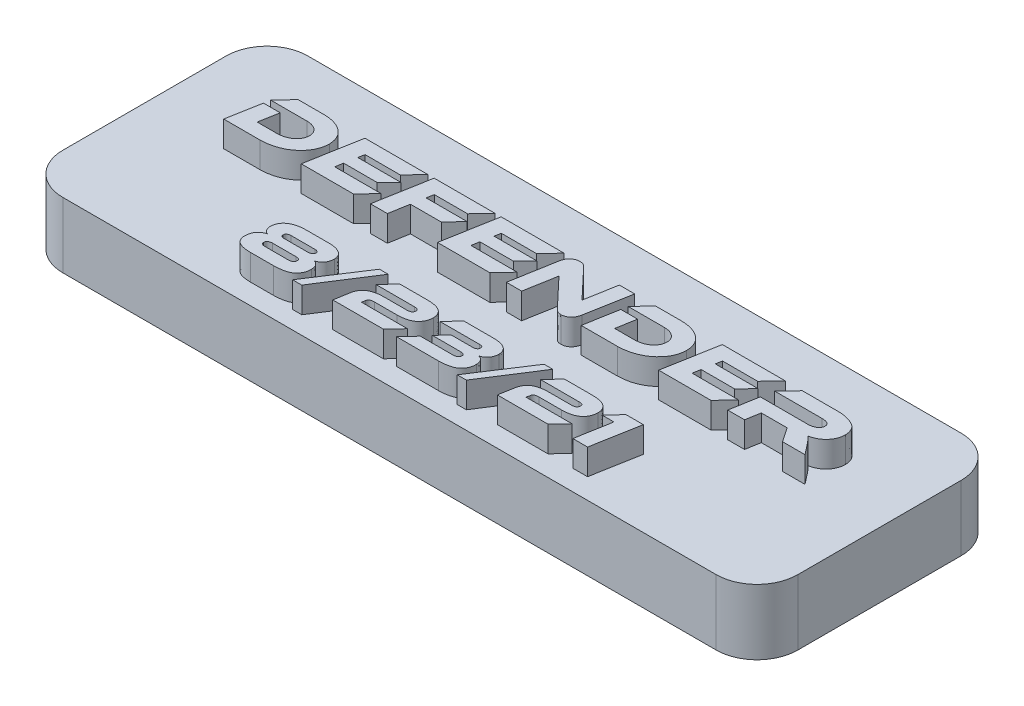
from build123d import *

# Parameters (mm, degrees)
SKETCH1_W           = 57.15
SKETCH1_H           = 19.05
BOSS_EXTRUDE1_DEPTH = 5.08
FILLET1_R           = 3.175
BOSS_EXTRUDE2_DEPTH = 2
SKETCH4_R           = 0.9
CUT_EXTRUDE1_DEPTH  = 4


with BuildPart() as part:
    # Sketch1 → Boss-Extrude1 (new body)
    with BuildSketch(Plane(origin=(0, 0, 0), x_dir=(1, 0, 0), z_dir=(0, 1, 0))):
        Rectangle(SKETCH1_W, SKETCH1_H)
    extrude(amount=BOSS_EXTRUDE1_DEPTH)

    # Fillet1
    fillet1_edges = [part.edges().sort_by_distance(p)[0] for p in [
        (-28.575, 2.54, -9.525),
        (-28.575, 2.54, 9.525),
        (28.575, 2.54, 9.525),
        (28.575, 2.54, -9.525),
    ]]
    fillet(fillet1_edges, radius=FILLET1_R)

    # Sketch3 → Boss-Extrude2 (add)
    with BuildSketch(Plane(origin=(0, 5.08, 0), x_dir=(1, 0, 0), z_dir=(0, 1, 0))):
        with BuildLine():
            add(Edge.make_bspline(
                [(22.1380192, 0.821261664), (22.110233075, 0.855514425), (22.057323504, 0.920737585), (21.983538164, 1.014147602), (21.914934978, 1.094728322), (21.854568887, 1.165931133), (21.798587752, 1.228233858), (21.747083376, 1.283693514), (21.698500493, 1.332710365), (21.666196618, 1.361916294), (21.650837295, 1.375802657)],
                knots=[0, 0, 0, 0, 0.000132319, 0.000251958, 0.000357066, 0.000449775, 0.000531993, 0.000608312, 0.000676831, 0.00073894, 0.00073894, 0.00073894, 0.00073894], degree=3))
            add(Edge.make_bspline(
                [(21.650837295, 1.375802657), (21.701282217, 1.387655917), (21.800614927, 1.41099655), (21.944581947, 1.456505146), (22.080420679, 1.512656797), (22.208390222, 1.577599655), (22.329176828, 1.650662326), (22.440901248, 1.734287933), (22.544639127, 1.827209607), (22.640194594, 1.928008098), (22.726061409, 2.036209783), (22.802275017, 2.148795776), (22.865521287, 2.26744033), (22.919187232, 2.389702633), (22.959689614, 2.517720245), (22.991843394, 2.649747841), (23.009453089, 2.787111939), (23.013584533, 2.88015474), (23.015670097, 2.927122995)],
                knots=[0, 0, 0, 0, 0.000155422, 0.000306047, 0.000452383, 0.000595882, 0.000736201, 0.000875336, 0.001013884, 0.001153561, 0.001291475, 0.00142788, 0.00156081, 0.001694289, 0.00182785, 0.001963107, 0.002101444, 0.002242464, 0.002242464, 0.002242464, 0.002242464], degree=3))
            add(Edge.make_bspline(
                [(23.015670097, 2.927122995), (23.01100645, 2.986733362), (23.002007489, 3.101757358), (22.965601322, 3.266295736), (22.913015681, 3.416602664), (22.842054216, 3.55250609), (22.753525997, 3.674215745), (22.645724254, 3.779555576), (22.522378714, 3.872802597), (22.380746955, 3.946152329), (22.230953308, 4.009923214), (22.076663938, 4.066098529), (21.918546122, 4.111445148), (21.757558489, 4.149301444), (21.592991154, 4.17747869), (21.425448915, 4.196572697), (21.254841422, 4.207081738), (21.140142863, 4.20637971), (21.08223314, 4.206025266)],
                knots=[0, 0, 0, 0, 0.000179195, 0.000345775, 0.000503934, 0.000655634, 0.000804102, 0.000953423, 0.00110627, 0.001266195, 0.001430402, 0.00159465, 0.001758393, 0.001923592, 0.002090563, 0.002258951, 0.002429281, 0.002602973, 0.002602973, 0.002602973, 0.002602973], degree=3))
            Line((21.08223314, 4.206025266), (18.365733505, 4.206347541))
            Line((18.365733505, 4.206347541), (17.316823245, 3.106887389))
            Line((17.316823245, 3.106887389), (20.994327892, 3.106887389))
            add(Edge.make_bspline(
                [(20.994327892, 3.106887389), (21.042289442, 3.105563142), (21.133101198, 3.103055777), (21.261206009, 3.084102014), (21.372826302, 3.053127658), (21.467185876, 3.008361144), (21.543352194, 2.950733271), (21.599088606, 2.878524615), (21.63231527, 2.792039639), (21.636080617, 2.729960255), (21.63803913, 2.697670193)],
                knots=[0, 0, 0, 0, 0.000143839, 0.000272348, 0.000387495, 0.000490117, 0.000583924, 0.00067132, 0.000760449, 0.00085706, 0.00085706, 0.00085706, 0.00085706], degree=3))
            add(Edge.make_bspline(
                [(21.63803913, 2.697670193), (21.636362091, 2.677195647), (21.6330541, 2.636809238), (21.620272862, 2.578009425), (21.600164385, 2.522994029), (21.572773444, 2.47158108), (21.539382067, 2.423095084), (21.497445133, 2.378841184), (21.448426997, 2.338813063), (21.374748783, 2.288346001), (21.270134405, 2.236864834), (21.132655227, 2.191707585), (20.98204979, 2.165412454), (20.877564865, 2.161339559), (20.823527391, 2.15923314)],
                knots=[0, 0, 0, 0, 6.1582e-05, 0.000121471, 0.000179891, 0.000236731, 0.000295819, 0.000355966, 0.000418937, 0.000485369, 0.000623551, 0.000766937, 0.000918284, 0.001080402, 0.001080402, 0.001080402, 0.001080402], degree=3))
            Line((20.823527391, 2.15923314), (17.146217359, 2.159459893))
            Line((17.146217359, 2.159459893), (16.767093168, 0.003655726))
            Line((16.767093168, 0.003655726), (18.075071626, 0.003655726))
            Line((18.075071626, 0.003655726), (18.270952457, 1.11686837))
            Line((18.270952457, 1.11686837), (20.280310667, 1.11686837))
            Line((20.280310667, 1.11686837), (21.025921574, 0.003655726))
            Line((21.025921574, 0.003655726), (22.776211587, 0.003655726))
            Line((22.776211587, 0.003655726), (22.1380192, 0.821261664))
        make_face()
        Polygon((12.901047708, 1.105536066), (13.002147492, 1.700326644), (15.605466933, 1.700326644), (16.51536499, 2.629107706), (13.172753378, 2.629107706), (13.261215689, 3.106887389), (15.997228597, 3.106887389), (17.03982012, 4.206347541), (12.149118064, 4.206347541), (11.397188419, 0.006075914), (15.46645473, 0.006075914), (16.502727517, 1.105536066), align=None)
        with BuildLine():
            add(Edge.make_bspline(
                [(11.159044007, 2.425376215), (11.156168293, 2.490366785), (11.150517883, 2.618064917), (11.118710503, 2.803986167), (11.070079895, 2.980115123), (11.004546328, 3.146960648), (10.918349172, 3.303299496), (10.81491754, 3.450058323), (10.692675159, 3.586303096), (10.554116067, 3.712179584), (10.399108664, 3.825344313), (10.230694299, 3.925395962), (10.048478763, 4.009390478), (9.853615227, 4.079106767), (9.645545385, 4.133528035), (9.424346333, 4.173811565), (9.189906687, 4.198189582), (9.029160673, 4.203371321), (8.946830966, 4.206025266)],
                knots=[0, 0, 0, 0, 0.000195009, 0.000383167, 0.000564368, 0.00074244, 0.000919581, 0.001098646, 0.001279935, 0.00146761, 0.001659228, 0.001854731, 0.002054318, 0.002260196, 0.002474835, 0.002698788, 0.00293411, 0.003181175, 0.003181175, 0.003181175, 0.003181175], degree=3))
            Line((8.946830966, 4.206025266), (6.950765493, 4.206347541))
            Line((6.950765493, 4.206347541), (5.920811442, 3.106887389))
            Line((5.920811442, 3.106887389), (8.751605398, 3.106887389))
            add(Edge.make_bspline(
                [(8.751605398, 3.106887389), (8.791117298, 3.105364711), (8.86833354, 3.102389015), (8.980955186, 3.089591847), (9.087648202, 3.069582481), (9.188496559, 3.04202105), (9.283858645, 3.008030543), (9.371989044, 2.964107485), (9.454852322, 2.914773344), (9.531615657, 2.858665576), (9.599530338, 2.795181395), (9.661208866, 2.72884043), (9.711039094, 2.655711823), (9.753852928, 2.579167986), (9.78808364, 2.49778013), (9.81107938, 2.411231968), (9.827610594, 2.320728819), (9.830337312, 2.258648084), (9.831732609, 2.22688058)],
                knots=[0, 0, 0, 0, 0.000118592, 0.000231759, 0.000339692, 0.000443921, 0.000545141, 0.000642853, 0.0007388, 0.00083424, 0.000927403, 0.001017368, 0.001105364, 0.001192113, 0.001280223, 0.00136938, 0.001460305, 0.001555592, 0.001555592, 0.001555592, 0.001555592], degree=3))
            add(Edge.make_bspline(
                [(9.831732609, 2.22688058), (9.829288164, 2.185642711), (9.824493425, 2.104755276), (9.801952724, 1.98706422), (9.76844647, 1.87545354), (9.721319, 1.770616802), (9.662073371, 1.672112744), (9.591784979, 1.579018173), (9.50720579, 1.493971369), (9.412767703, 1.414841832), (9.308550422, 1.343689091), (9.196895574, 1.281927096), (9.079262119, 1.227960987), (8.953992364, 1.185692043), (8.822831026, 1.150471437), (8.684482932, 1.126576329), (8.540156125, 1.109169924), (8.441357747, 1.106548421), (8.391024976, 1.105212899)],
                knots=[0, 0, 0, 0, 0.00012382, 0.000242871, 0.000358539, 0.000472706, 0.000586683, 0.000702784, 0.000821729, 0.000945681, 0.001071953, 0.001199634, 0.001328098, 0.001459638, 0.001595783, 0.001735109, 0.00188048, 0.002031451, 0.002031451, 0.002031451, 0.002031451], degree=3))
            Line((8.391024976, 1.105212899), (6.874940655, 1.105536066))
            Line((6.874940655, 1.105536066), (7.146646325, 2.623662059))
            Line((7.146646325, 2.623662059), (5.838667868, 2.623662059))
            Line((5.838667868, 2.623662059), (5.371081366, 0.006075914))
            Line((5.371081366, 0.006075914), (8.201875321, 0.006075914))
            add(Edge.make_bspline(
                [(8.201875321, 0.006075914), (8.303742698, 0.00973645), (8.503898635, 0.016928919), (8.797276314, 0.055361686), (9.077869848, 0.113609118), (9.345746371, 0.192345638), (9.601188437, 0.290947451), (9.843364969, 0.411678855), (10.07381561, 0.551302588), (10.253190091, 0.685730436), (10.388476432, 0.801137626), (10.483667045, 0.891127884), (10.573157595, 0.98286194), (10.656050912, 1.077854124), (10.732812359, 1.175378809), (10.802988026, 1.275986307), (10.867715967, 1.378755373), (10.924846299, 1.484675691), (10.976421352, 1.592866707), (11.021309622, 1.703675086), (11.059516561, 1.817381495), (11.092613976, 1.933500983), (11.119470155, 2.052449268), (11.137947308, 2.174419147), (11.152379566, 2.298802205), (11.156229286, 2.38285802), (11.159044007, 2.425376215)],
                knots=[0, 0, 0, 0, 0.000305659, 0.00060058, 0.000886364, 0.001164634, 0.001437273, 0.001706688, 0.001975409, 0.002244537, 0.002378097, 0.002508729, 0.002637378, 0.002762417, 0.002886772, 0.003009517, 0.003130255, 0.003250927, 0.003370328, 0.003489667, 0.003609348, 0.003730019, 0.003851781, 0.003974869, 0.004099948, 0.004227226, 0.004227226, 0.004227226, 0.004227226], degree=3))
        make_face()
        with BuildLine():
            add(Edge.make_bspline(
                [(3.850463767, -0.054850168), (3.898207164, -0.053307756), (3.992909305, -0.05024828), (4.130965687, -0.013632566), (4.261880399, 0.045846546), (4.363145933, 0.114571327), (4.440010596, 0.180074196), (4.491662878, 0.239380304), (4.539338865, 0.304525883), (4.583017611, 0.37632488), (4.619747247, 0.456142621), (4.652863868, 0.542520209), (4.68129352, 0.636006561), (4.695839595, 0.701351948), (4.703325362, 0.73498029)],
                knots=[0, 0, 0, 0, 0.000142918, 0.000283487, 0.000425039, 0.000572601, 0.000649052, 0.000727397, 0.000807848, 0.000891096, 0.000979017, 0.001071034, 0.001168489, 0.001271817, 0.001271817, 0.001271817, 0.001271817], degree=3))
            Line((4.703325362, 0.73498029), (5.32904811, 4.208766837))
            Line((5.32904811, 4.208766837), (4.141125646, 4.208766837))
            Line((4.141125646, 4.208766837), (3.698814091, 1.744535481))
            Line((3.698814091, 1.744535481), (1.518849996, 4.051761679))
            add(Edge.make_bspline(
                [(1.518849996, 4.051761679), (1.498010869, 4.071861366), (1.457946596, 4.110504029), (1.395368732, 4.159915527), (1.333330986, 4.198286334), (1.253493604, 4.234148727), (1.153217036, 4.262967857), (1.071894605, 4.265244744), (1.032080531, 4.266359469)],
                knots=[0, 0, 0, 0, 8.6821e-05, 0.000166918, 0.000238724, 0.000304999, 0.000429193, 0.000548317, 0.000548317, 0.000548317, 0.000548317], degree=3))
            add(Edge.make_bspline(
                [(1.032080531, 4.266359469), (0.982803487, 4.264808905), (0.885756899, 4.261755212), (0.744614186, 4.225895662), (0.610878482, 4.169094021), (0.508319479, 4.10078741), (0.431804247, 4.035125752), (0.379928882, 3.976716804), (0.331780493, 3.912614286), (0.289717796, 3.840326612), (0.252402196, 3.76109782), (0.22083087, 3.674633708), (0.192616086, 3.581734028), (0.179533433, 3.516584051), (0.172775217, 3.482928986)],
                knots=[0, 0, 0, 0, 0.000147522, 0.000290531, 0.000433852, 0.000581668, 0.000658119, 0.000735785, 0.0008155, 0.00089828, 0.000986201, 0.001077895, 0.001174211, 0.001277134, 0.001277134, 0.001277134, 0.001277134], degree=3))
            Line((0.172775217, 3.482928986), (-0.439958322, 0.003655726))
            Line((-0.439958322, 0.003655726), (0.747964142, 0.003655726))
            Line((0.747964142, 0.003655726), (1.183956961, 2.467622834))
            Line((1.183956961, 2.467622834), (3.363921056, 0.160396636))
            add(Edge.make_bspline(
                [(3.363921056, 0.160396636), (3.384638161, 0.140042889), (3.42424306, 0.101132624), (3.486374612, 0.052046216), (3.545934438, 0.012533377), (3.62346331, -0.024191848), (3.72515749, -0.051598076), (3.808187255, -0.054359084), (3.850463767, -0.054850168)],
                knots=[0, 0, 0, 0, 8.7067e-05, 0.000166446, 0.000237191, 0.000300979, 0.000423168, 0.000549653, 0.000549653, 0.000549653, 0.000549653], degree=3))
        make_face()
        Polygon((-4.299685046, 1.105536066), (-4.198585261, 1.700326644), (-1.59526582, 1.700326644), (-0.685367763, 2.629107706), (-4.027979376, 2.629107706), (-3.939517065, 3.106887389), (-1.203504157, 3.106887389), (-0.160912633, 4.206347541), (-5.05161469, 4.206347541), (-5.803544334, 0.006075914), (-1.734278024, 0.006075914), (-0.698005236, 1.105536066), align=None)
        Polygon((-10.258639231, 4.206347541), (-11.010568875, 0.003655726), (-9.696271682, 0.003655726), (-9.424566012, 1.53029389), (-7.029764876, 1.53029389), (-6.056679454, 2.565116885), (-9.241322653, 2.565116885), (-9.146541606, 3.106887389), (-6.562178374, 3.106887389), (-5.525905587, 4.206347541), align=None)
        Polygon((-14.889251809, 1.105536066), (-14.788152025, 1.700326644), (-12.184832584, 1.700326644), (-11.274934527, 2.629107706), (-14.617546139, 2.629107706), (-14.529083828, 3.106887389), (-11.79307092, 3.106887389), (-10.750479397, 4.206347541), (-15.641181453, 4.206347541), (-16.393111098, 0.006075914), (-12.323844787, 0.006075914), (-11.287572, 1.105536066), align=None)
        with BuildLine():
            add(Edge.make_bspline(
                [(-16.63125551, 2.425376215), (-16.634131224, 2.490366785), (-16.639781634, 2.618064917), (-16.671589014, 2.803986167), (-16.720219622, 2.980115123), (-16.785753189, 3.146960648), (-16.871950345, 3.303299496), (-16.975381976, 3.450058323), (-17.097624357, 3.586303096), (-17.23618345, 3.712179584), (-17.391190853, 3.825344313), (-17.559605218, 3.925395962), (-17.741820753, 4.009390478), (-17.93668429, 4.079106767), (-18.144754132, 4.133528035), (-18.365953184, 4.173811565), (-18.600392829, 4.198189582), (-18.761138844, 4.203371321), (-18.843468551, 4.206025266)],
                knots=[0, 0, 0, 0, 0.000195009, 0.000383167, 0.000564368, 0.00074244, 0.000919581, 0.001098646, 0.001279935, 0.00146761, 0.001659228, 0.001854731, 0.002054318, 0.002260196, 0.002474835, 0.002698788, 0.00293411, 0.003181175, 0.003181175, 0.003181175, 0.003181175], degree=3))
            Line((-18.843468551, 4.206025266), (-20.839534024, 4.206347541))
            Line((-20.839534024, 4.206347541), (-21.869488075, 3.106887389))
            Line((-21.869488075, 3.106887389), (-19.038694119, 3.106887389))
            add(Edge.make_bspline(
                [(-19.038694119, 3.106887389), (-18.999182219, 3.105364711), (-18.921965977, 3.102389015), (-18.809344331, 3.089591847), (-18.702651315, 3.069582481), (-18.601802958, 3.04202105), (-18.506440872, 3.008030543), (-18.418310473, 2.964107485), (-18.335447195, 2.914773344), (-18.25868386, 2.858665576), (-18.190769179, 2.795181395), (-18.129090651, 2.72884043), (-18.079260423, 2.655711823), (-18.036446589, 2.579167986), (-18.002215877, 2.49778013), (-17.979220137, 2.411231968), (-17.962688923, 2.320728819), (-17.959962205, 2.258648084), (-17.958566908, 2.22688058)],
                knots=[0, 0, 0, 0, 0.000118592, 0.000231759, 0.000339692, 0.000443921, 0.000545141, 0.000642853, 0.0007388, 0.00083424, 0.000927403, 0.001017368, 0.001105364, 0.001192113, 0.001280223, 0.00136938, 0.001460305, 0.001555592, 0.001555592, 0.001555592, 0.001555592], degree=3))
            add(Edge.make_bspline(
                [(-17.958566908, 2.22688058), (-17.961011353, 2.185642711), (-17.965806092, 2.104755276), (-17.988346793, 1.98706422), (-18.021853047, 1.87545354), (-18.068980517, 1.770616802), (-18.128226146, 1.672112744), (-18.198514538, 1.579018173), (-18.283093727, 1.493971369), (-18.377531814, 1.414841832), (-18.481749094, 1.343689091), (-18.593403943, 1.281927096), (-18.711037398, 1.227960987), (-18.836307153, 1.185692043), (-18.967468491, 1.150471437), (-19.105816585, 1.126576329), (-19.250143392, 1.109169924), (-19.34894177, 1.106548421), (-19.399274541, 1.105212899)],
                knots=[0, 0, 0, 0, 0.00012382, 0.000242871, 0.000358539, 0.000472706, 0.000586683, 0.000702784, 0.000821729, 0.000945681, 0.001071953, 0.001199634, 0.001328098, 0.001459638, 0.001595783, 0.001735109, 0.00188048, 0.002031451, 0.002031451, 0.002031451, 0.002031451], degree=3))
            Line((-19.399274541, 1.105212899), (-20.915358862, 1.105536066))
            Line((-20.915358862, 1.105536066), (-20.643653192, 2.623662059))
            Line((-20.643653192, 2.623662059), (-21.951631649, 2.623662059))
            Line((-21.951631649, 2.623662059), (-22.419218151, 0.006075914))
            Line((-22.419218151, 0.006075914), (-19.588424195, 0.006075914))
            add(Edge.make_bspline(
                [(-19.588424195, 0.006075914), (-19.486556819, 0.00973645), (-19.286400882, 0.016928919), (-18.993023203, 0.055361686), (-18.712429669, 0.113609118), (-18.444553146, 0.192345638), (-18.18911108, 0.290947451), (-17.946934548, 0.411678855), (-17.716483907, 0.551302588), (-17.537109425, 0.685730436), (-17.401823085, 0.801137626), (-17.306632471, 0.891127884), (-17.217141922, 0.98286194), (-17.134248605, 1.077854124), (-17.057487158, 1.175378809), (-16.987311491, 1.275986307), (-16.92258355, 1.378755373), (-16.865453218, 1.484675691), (-16.813878165, 1.592866707), (-16.768989895, 1.703675086), (-16.730782956, 1.817381495), (-16.697685541, 1.933500983), (-16.670829362, 2.052449268), (-16.652352209, 2.174419147), (-16.637919951, 2.298802205), (-16.634070231, 2.38285802), (-16.63125551, 2.425376215)],
                knots=[0, 0, 0, 0, 0.000305659, 0.00060058, 0.000886364, 0.001164634, 0.001437273, 0.001706688, 0.001975409, 0.002244537, 0.002378097, 0.002508729, 0.002637378, 0.002762417, 0.002886772, 0.003009517, 0.003130255, 0.003250927, 0.003370328, 0.003489667, 0.003609348, 0.003730019, 0.003851781, 0.003974869, 0.004099948, 0.004227226, 0.004227226, 0.004227226, 0.004227226], degree=3))
        make_face()
        Polygon((12.244882676, -5.218973535), (13.14609247, -5.218973535), (12.665078653, -7.93430124), (13.809559803, -7.93430124), (14.467498242, -4.256945902), (13.112919103, -4.256945902), align=None)
        with BuildLine():
            Line((7.428273562, -5.218973535), (10.419405457, -5.218973535))
            add(Edge.make_bspline(
                [(10.419405457, -5.218973535), (10.447106371, -5.218922741), (10.498952745, -5.218827674), (10.571681748, -5.225918073), (10.63320579, -5.242216387), (10.685036327, -5.26353583), (10.725129716, -5.294908436), (10.753443715, -5.334273792), (10.770995693, -5.381008794), (10.772220392, -5.4147712), (10.772854758, -5.432259348)],
                knots=[0, 0, 0, 0, 8.3099e-05, 0.000155531, 0.000218392, 0.000273538, 0.000322508, 0.000368908, 0.000417497, 0.000469711, 0.000469711, 0.000469711, 0.000469711], degree=3))
            add(Edge.make_bspline(
                [(10.772854758, -5.432259348), (10.772214965, -5.458018948), (10.77100536, -5.506720508), (10.750442975, -5.573936821), (10.717156599, -5.630194031), (10.667942975, -5.673414306), (10.604411877, -5.704561408), (10.52667771, -5.726311626), (10.43355255, -5.738498194), (10.366550906, -5.73961472), (10.330518207, -5.740215175)],
                knots=[0, 0, 0, 0, 7.6993e-05, 0.000145564, 0.000208395, 0.000270703, 0.000339032, 0.00041902, 0.000511893, 0.000619952, 0.000619952, 0.000619952, 0.000619952], degree=3))
            Line((10.330518207, -5.740215175), (8.572754712, -5.739416071))
            add(Edge.make_bspline(
                [(8.572754712, -5.739416071), (8.517152556, -5.740560639), (8.408899394, -5.742789025), (8.250904068, -5.753609346), (8.102184708, -5.772857955), (7.96256184, -5.798779792), (7.832298642, -5.833149331), (7.71121979, -5.875619954), (7.59895241, -5.92500466), (7.495750542, -5.98174212), (7.402281346, -6.047028209), (7.317755853, -6.120143527), (7.242355244, -6.201107035), (7.176354221, -6.289606037), (7.119972648, -6.385733808), (7.072876893, -6.489539314), (7.03392953, -6.600822081), (7.016607854, -6.678800473), (7.007794813, -6.718474855)],
                knots=[0, 0, 0, 0, 0.000166829, 0.000324804, 0.000474816, 0.000616477, 0.000750546, 0.000878553, 0.001001026, 0.001118108, 0.001231277, 0.001342418, 0.001452782, 0.001562526, 0.00167296, 0.001786425, 0.001904052, 0.002025887, 0.002025887, 0.002025887, 0.002025887], degree=3))
            Line((7.007794813, -6.718474855), (6.792450701, -7.932183575))
            Line((6.792450701, -7.932183575), (10.729023546, -7.932183575))
            Line((10.729023546, -7.932183575), (11.635762234, -6.970155942))
            Line((11.635762234, -6.970155942), (8.064096424, -6.970155942))
            Line((8.064096424, -6.970155942), (8.113856474, -6.707239748))
            add(Edge.make_bspline(
                [(8.113856474, -6.707239748), (8.117633997, -6.686112106), (8.124956754, -6.645156023), (8.153668107, -6.590591717), (8.1920288, -6.543848716), (8.243368132, -6.508043577), (8.304443599, -6.47963759), (8.376761219, -6.461031101), (8.45982464, -6.450993538), (8.51874815, -6.450679637), (8.549973605, -6.450513291)],
                knots=[0, 0, 0, 0, 6.4036e-05, 0.000124134, 0.000182613, 0.000243892, 0.000310094, 0.000383827, 0.000466868, 0.000560486, 0.000560486, 0.000560486, 0.000560486], degree=3))
            Line((8.549973605, -6.450513291), (10.308827568, -6.449714187))
            add(Edge.make_bspline(
                [(10.308827568, -6.449714187), (10.374508593, -6.448593152), (10.501843033, -6.446419826), (10.685740882, -6.426694059), (10.857157493, -6.400940141), (11.015004379, -6.361961645), (11.160758372, -6.315052912), (11.292099627, -6.255202462), (11.411572743, -6.187512089), (11.516285182, -6.107690588), (11.608868374, -6.020066732), (11.689324736, -5.925525662), (11.757103621, -5.823724541), (11.812856422, -5.715194429), (11.854992392, -5.599220599), (11.885687828, -5.476792913), (11.903343173, -5.347458364), (11.905296127, -5.259004345), (11.90629218, -5.21389067)],
                knots=[0, 0, 0, 0, 0.00019697, 0.000381861, 0.000554393, 0.000716581, 0.000869107, 0.001013024, 0.00114885, 0.001280192, 0.001406932, 0.001530654, 0.001651783, 0.001773055, 0.001895792, 0.002021116, 0.002151095, 0.002286391, 0.002286391, 0.002286391, 0.002286391], degree=3))
            add(Edge.make_bspline(
                [(11.90629218, -5.21389067), (11.905839725, -5.1780961), (11.90495398, -5.108023129), (11.888744133, -5.005989197), (11.864752061, -4.909275966), (11.828217358, -4.818686266), (11.780583005, -4.734234215), (11.722503963, -4.655338408), (11.654136336, -4.582231577), (11.574841896, -4.515185386), (11.484018979, -4.455053695), (11.380440358, -4.402688892), (11.264207238, -4.359688685), (11.136019759, -4.322394884), (10.99521675, -4.294289614), (10.841869704, -4.27367202), (10.676003173, -4.26108405), (10.561173558, -4.258543735), (10.501693653, -4.257227893)],
                knots=[0, 0, 0, 0, 0.000107259, 0.000209975, 0.000309113, 0.00040566, 0.000501999, 0.00059927, 0.000698874, 0.0008016, 0.000910084, 0.001024914, 0.001148961, 0.001281358, 0.001425053, 0.00157924, 0.00174531, 0.001923772, 0.001923772, 0.001923772, 0.001923772], degree=3))
            Line((10.501693653, -4.257227893), (8.335012251, -4.256945902))
            Line((8.335012251, -4.256945902), (7.428273562, -5.218973535))
        make_face()
        Polygon((6.542463122, -4.05005839), (3.877536, -8.139071868), (4.590763383, -8.139071868), (7.216988244, -4.05005839), align=None)
        with BuildLine():
            Line((-1.050882076, -7.932183575), (2.205636752, -7.932183575))
            add(Edge.make_bspline(
                [(2.205636752, -7.932183575), (2.247653049, -7.93123587), (2.329977745, -7.929378983), (2.450973636, -7.923037277), (2.56669151, -7.913254577), (2.67746677, -7.901623973), (2.782768189, -7.886187648), (2.882953693, -7.869042189), (2.977552862, -7.847894486), (3.066782806, -7.825100472), (3.150898313, -7.799290342), (3.229426228, -7.77082736), (3.303017268, -7.739583859), (3.370857346, -7.704897995), (3.434384464, -7.668886302), (3.491295219, -7.627851966), (3.544317602, -7.586408565), (3.60554179, -7.526093275), (3.673753384, -7.447939794), (3.744330436, -7.349103621), (3.804098391, -7.247349748), (3.851603168, -7.141977162), (3.887076621, -7.033365496), (3.910354643, -6.921258258), (3.921787639, -6.805632209), (3.920226984, -6.727558847), (3.919437802, -6.688079215)],
                knots=[0, 0, 0, 0, 0.000126077, 0.000247029, 0.000363409, 0.000474443, 0.000581116, 0.000682639, 0.000779289, 0.000871831, 0.000958868, 0.001043129, 0.001122322, 0.001198517, 0.00127164, 0.001341101, 0.001408809, 0.001473297, 0.001598583, 0.001719557, 0.001837129, 0.001952051, 0.002065626, 0.002179204, 0.002294931, 0.002413314, 0.002413314, 0.002413314, 0.002413314], degree=3))
            add(Edge.make_bspline(
                [(3.919437802, -6.688079215), (3.917415159, -6.645034748), (3.913522616, -6.562196351), (3.888977695, -6.444259027), (3.847764176, -6.339492999), (3.792315203, -6.247902175), (3.723534676, -6.171048672), (3.645716096, -6.10652163), (3.557639372, -6.055707807), (3.493032957, -6.034777591), (3.460303659, -6.024174444)],
                knots=[0, 0, 0, 0, 0.000129139, 0.000248525, 0.000359482, 0.000465388, 0.000567951, 0.000667397, 0.000767703, 0.000870689, 0.000870689, 0.000870689, 0.000870689], degree=3))
            add(Edge.make_bspline(
                [(3.460303659, -6.024174444), (3.501634315, -6.009960653), (3.584918465, -5.981318874), (3.70137863, -5.914739414), (3.811105638, -5.831227741), (3.895930325, -5.748532962), (3.957321397, -5.672798575), (3.998648462, -5.610121102), (4.032736194, -5.541280496), (4.062382129, -5.468161351), (4.085893933, -5.389726388), (4.101946768, -5.306040388), (4.114657623, -5.217443624), (4.117272257, -5.156345524), (4.118609233, -5.125103406)],
                knots=[0, 0, 0, 0, 0.000130881, 0.000263734, 0.000400196, 0.000543864, 0.000617818, 0.000692362, 0.000768557, 0.000847875, 0.000928857, 0.001013724, 0.001103318, 0.001197072, 0.001197072, 0.001197072, 0.001197072], degree=3))
            add(Edge.make_bspline(
                [(4.118609233, -5.125103406), (4.117269487, -5.090373417), (4.114666496, -5.022896543), (4.09761977, -4.924759117), (4.069552502, -4.833556952), (4.031815209, -4.74840209), (3.983283819, -4.670190772), (3.924622091, -4.598383368), (3.854571775, -4.534139714), (3.775418727, -4.475547046), (3.686087363, -4.424861588), (3.58892933, -4.380021469), (3.483633035, -4.341403135), (3.369842882, -4.310565354), (3.24794321, -4.286619559), (3.117774053, -4.270262105), (2.979477749, -4.259706834), (2.884406274, -4.258068877), (2.835593267, -4.257227893)],
                knots=[0, 0, 0, 0, 0.000104182, 0.000202415, 0.000297803, 0.000389821, 0.000481053, 0.000573127, 0.000667078, 0.000765468, 0.000867956, 0.000974605, 0.001086203, 0.001203992, 0.00132792, 0.001458586, 0.001597356, 0.00174379, 0.00174379, 0.00174379, 0.00174379], degree=3))
            Line((2.835593267, -4.257227893), (0.519323946, -4.256945902))
            Line((0.519323946, -4.256945902), (-0.387414742, -5.218973535))
            Line((-0.387414742, -5.218973535), (2.708766146, -5.218973535))
            add(Edge.make_bspline(
                [(2.708766146, -5.218973535), (2.726819025, -5.219195663), (2.761904841, -5.219627369), (2.812643838, -5.228283394), (2.86030391, -5.240429742), (2.903108887, -5.259411957), (2.940646202, -5.284007636), (2.968948784, -5.317589756), (2.985087677, -5.359825366), (2.988288512, -5.390000635), (2.989971123, -5.405863134)],
                knots=[0, 0, 0, 0, 5.4079e-05, 0.000105103, 0.000154, 0.000201268, 0.000244977, 0.000287582, 0.000330657, 0.000378396, 0.000378396, 0.000378396, 0.000378396], degree=3))
            add(Edge.make_bspline(
                [(2.989971123, -5.405863134), (2.988132805, -5.430312402), (2.984658044, -5.476526055), (2.962828494, -5.540002066), (2.927542294, -5.592061965), (2.878531149, -5.629761186), (2.822217039, -5.655905201), (2.761001619, -5.675731181), (2.69468487, -5.686777079), (2.648725724, -5.68773353), (2.625223442, -5.688222633)],
                knots=[0, 0, 0, 0, 7.3319e-05, 0.000138587, 0.00019894, 0.000259277, 0.000321525, 0.000384513, 0.000451841, 0.000522304, 0.000522304, 0.000522304, 0.000522304], degree=3))
            Line((2.625223442, -5.688222633), (0.98375108, -5.688222633))
            Line((0.98375108, -5.688222633), (0.248408119, -6.449714187))
            Line((0.248408119, -6.449714187), (2.465494791, -6.449714187))
            add(Edge.make_bspline(
                [(2.465494791, -6.449714187), (2.491052922, -6.450477347), (2.538756138, -6.451901753), (2.605295971, -6.462295485), (2.661715231, -6.478314945), (2.708378703, -6.50173535), (2.744619024, -6.532597577), (2.770612628, -6.570559095), (2.784383688, -6.615980043), (2.785442091, -6.647995141), (2.78600038, -6.664882542)],
                knots=[0, 0, 0, 0, 7.6645e-05, 0.000143055, 0.000201512, 0.000251956, 0.000298459, 0.000342829, 0.000388113, 0.000438664, 0.000438664, 0.000438664, 0.000438664], degree=3))
            add(Edge.make_bspline(
                [(2.78600038, -6.664882542), (2.785524377, -6.688229704), (2.784614959, -6.732835091), (2.765387495, -6.795336816), (2.733819259, -6.849505947), (2.686599623, -6.892453142), (2.627947389, -6.927804649), (2.55496638, -6.950272738), (2.47024498, -6.966892139), (2.409088783, -6.969204801), (2.376459124, -6.970438714)],
                knots=[0, 0, 0, 0, 6.9755e-05, 0.000133269, 0.000193903, 0.000255577, 0.000322658, 0.000397783, 0.000483281, 0.000581077, 0.000581077, 0.000581077, 0.000581077], degree=3))
            Line((2.376459124, -6.970438714), (-0.155201176, -6.970155942))
            Line((-0.155201176, -6.970155942), (-1.050882076, -7.932183575))
        make_face()
        with BuildLine():
            Line((-5.369890689, -5.218973535), (-2.378758795, -5.218973535))
            add(Edge.make_bspline(
                [(-2.378758795, -5.218973535), (-2.351057881, -5.218922741), (-2.299211506, -5.218827674), (-2.226482503, -5.225918073), (-2.164958461, -5.242216387), (-2.113127925, -5.26353583), (-2.073034535, -5.294908436), (-2.044720536, -5.334273792), (-2.027168558, -5.381008794), (-2.025943859, -5.4147712), (-2.025309493, -5.432259348)],
                knots=[0, 0, 0, 0, 8.3099e-05, 0.000155531, 0.000218392, 0.000273538, 0.000322508, 0.000368908, 0.000417497, 0.000469711, 0.000469711, 0.000469711, 0.000469711], degree=3))
            add(Edge.make_bspline(
                [(-2.025309493, -5.432259348), (-2.025949286, -5.458018948), (-2.027158891, -5.506720508), (-2.047721276, -5.573936821), (-2.081007653, -5.630194031), (-2.130221276, -5.673414306), (-2.193752374, -5.704561408), (-2.271486541, -5.726311626), (-2.364611701, -5.738498194), (-2.431613345, -5.73961472), (-2.467646045, -5.740215175)],
                knots=[0, 0, 0, 0, 7.6993e-05, 0.000145564, 0.000208395, 0.000270703, 0.000339032, 0.00041902, 0.000511893, 0.000619952, 0.000619952, 0.000619952, 0.000619952], degree=3))
            Line((-2.467646045, -5.740215175), (-4.225409539, -5.739416071))
            add(Edge.make_bspline(
                [(-4.225409539, -5.739416071), (-4.281011695, -5.740560639), (-4.389264857, -5.742789025), (-4.547260183, -5.753609346), (-4.695979543, -5.772857955), (-4.835602411, -5.798779792), (-4.965865609, -5.833149331), (-5.086944461, -5.875619954), (-5.199211841, -5.92500466), (-5.302413709, -5.98174212), (-5.395882906, -6.047028209), (-5.480408399, -6.120143527), (-5.555809008, -6.201107035), (-5.62181003, -6.289606037), (-5.678191603, -6.385733808), (-5.725287358, -6.489539314), (-5.764234721, -6.600822081), (-5.781556397, -6.678800473), (-5.790369438, -6.718474855)],
                knots=[0, 0, 0, 0, 0.000166829, 0.000324804, 0.000474816, 0.000616477, 0.000750546, 0.000878553, 0.001001026, 0.001118108, 0.001231277, 0.001342418, 0.001452782, 0.001562526, 0.00167296, 0.001786425, 0.001904052, 0.002025887, 0.002025887, 0.002025887, 0.002025887], degree=3))
            Line((-5.790369438, -6.718474855), (-6.00571355, -7.932183575))
            Line((-6.00571355, -7.932183575), (-2.069140706, -7.932183575))
            Line((-2.069140706, -7.932183575), (-1.162402017, -6.970155942))
            Line((-1.162402017, -6.970155942), (-4.734067828, -6.970155942))
            Line((-4.734067828, -6.970155942), (-4.684307778, -6.707239748))
            add(Edge.make_bspline(
                [(-4.684307778, -6.707239748), (-4.680530254, -6.686112106), (-4.673207497, -6.645156023), (-4.644496144, -6.590591717), (-4.606135451, -6.543848716), (-4.554796119, -6.508043577), (-4.493720653, -6.47963759), (-4.421403033, -6.461031101), (-4.338339611, -6.450993538), (-4.279416101, -6.450679637), (-4.248190646, -6.450513291)],
                knots=[0, 0, 0, 0, 6.4036e-05, 0.000124134, 0.000182613, 0.000243892, 0.000310094, 0.000383827, 0.000466868, 0.000560486, 0.000560486, 0.000560486, 0.000560486], degree=3))
            Line((-4.248190646, -6.450513291), (-2.489336683, -6.449714187))
            add(Edge.make_bspline(
                [(-2.489336683, -6.449714187), (-2.423655658, -6.448593152), (-2.296321218, -6.446419826), (-2.112423369, -6.426694059), (-1.941006758, -6.400940141), (-1.783159872, -6.361961645), (-1.637405879, -6.315052912), (-1.506064624, -6.255202462), (-1.386591508, -6.187512089), (-1.281879069, -6.107690588), (-1.189295877, -6.020066732), (-1.108839515, -5.925525662), (-1.041060631, -5.823724541), (-0.985307829, -5.715194429), (-0.943171859, -5.599220599), (-0.912476423, -5.476792913), (-0.894821078, -5.347458364), (-0.892868125, -5.259004345), (-0.891872071, -5.21389067)],
                knots=[0, 0, 0, 0, 0.00019697, 0.000381861, 0.000554393, 0.000716581, 0.000869107, 0.001013024, 0.00114885, 0.001280192, 0.001406932, 0.001530654, 0.001651783, 0.001773055, 0.001895792, 0.002021116, 0.002151095, 0.002286391, 0.002286391, 0.002286391, 0.002286391], degree=3))
            add(Edge.make_bspline(
                [(-0.891872071, -5.21389067), (-0.892324526, -5.1780961), (-0.893210271, -5.108023129), (-0.909420118, -5.005989197), (-0.93341219, -4.909275966), (-0.969946894, -4.818686266), (-1.017581246, -4.734234215), (-1.075660288, -4.655338408), (-1.144027915, -4.582231577), (-1.223322355, -4.515185386), (-1.314145272, -4.455053695), (-1.417723893, -4.402688892), (-1.533957013, -4.359688685), (-1.662144492, -4.322394884), (-1.802947501, -4.294289614), (-1.956294547, -4.27367202), (-2.122161078, -4.26108405), (-2.236990694, -4.258543735), (-2.296470598, -4.257227893)],
                knots=[0, 0, 0, 0, 0.000107259, 0.000209975, 0.000309113, 0.00040566, 0.000501999, 0.00059927, 0.000698874, 0.0008016, 0.000910084, 0.001024914, 0.001148961, 0.001281358, 0.001425053, 0.00157924, 0.00174531, 0.001923772, 0.001923772, 0.001923772, 0.001923772], degree=3))
            Line((-2.296470598, -4.257227893), (-4.463152, -4.256945902))
            Line((-4.463152, -4.256945902), (-5.369890689, -5.218973535))
        make_face()
        Polygon((-6.255701129, -4.05005839), (-8.920628251, -8.139071868), (-8.207400868, -8.139071868), (-5.581176007, -4.05005839), align=None)
        with BuildLine():
            add(Edge.make_bspline(
                [(-10.601862098, -7.932183575), (-10.56020054, -7.931231171), (-10.478230891, -7.929357303), (-10.357589693, -7.92303202), (-10.242133281, -7.913299393), (-10.131892881, -7.901630571), (-10.027136775, -7.886120178), (-9.927214731, -7.869023985), (-9.832837447, -7.848038176), (-9.743963221, -7.824924016), (-9.66025086, -7.79951071), (-9.581946346, -7.770456276), (-9.508149758, -7.739757788), (-9.440201187, -7.705166947), (-9.377204523, -7.668342595), (-9.3197786, -7.628415757), (-9.267427319, -7.586096005), (-9.206143314, -7.52618861), (-9.138078125, -7.44788067), (-9.067343826, -7.349322028), (-9.008421552, -7.24731168), (-8.961906918, -7.14179993), (-8.926236959, -7.033385143), (-8.903020623, -6.921252912), (-8.891571019, -6.805633592), (-8.893133941, -6.727559312), (-8.893924269, -6.688079215)],
                knots=[0, 0, 0, 0, 0.000125013, 0.000245965, 0.000362345, 0.000472585, 0.000578466, 0.000679988, 0.000776639, 0.000868406, 0.000955443, 0.001038954, 0.001118882, 0.001195077, 0.00126751, 0.001337627, 0.001404712, 0.001469201, 0.001594487, 0.00171546, 0.001832632, 0.001947228, 0.002060803, 0.002174381, 0.002290108, 0.002408491, 0.002408491, 0.002408491, 0.002408491], degree=3))
            add(Edge.make_bspline(
                [(-8.893924269, -6.688079215), (-8.895893167, -6.645013118), (-8.89968228, -6.562133096), (-8.924900724, -6.444672392), (-8.963560039, -6.339091581), (-9.019651782, -6.248261694), (-9.087334525, -6.170723555), (-9.165057795, -6.10705473), (-9.251602966, -6.055649416), (-9.315235448, -6.034755311), (-9.347459215, -6.024174444)],
                knots=[0, 0, 0, 0, 0.000129139, 0.000248525, 0.000358904, 0.000464809, 0.000566844, 0.000666291, 0.000765209, 0.000866693, 0.000866693, 0.000866693, 0.000866693], degree=3))
            add(Edge.make_bspline(
                [(-9.347459215, -6.024174444), (-9.306128559, -6.009960653), (-9.222844409, -5.981318874), (-9.106384245, -5.914739414), (-8.996657237, -5.831227741), (-8.911832549, -5.748532962), (-8.850441478, -5.672798575), (-8.809114413, -5.610121102), (-8.775026681, -5.541280496), (-8.745380746, -5.468161351), (-8.721868941, -5.389726388), (-8.705816106, -5.306040388), (-8.693105252, -5.217443624), (-8.690490617, -5.156345524), (-8.689153641, -5.125103406)],
                knots=[0, 0, 0, 0, 0.000130881, 0.000263734, 0.000400196, 0.000543864, 0.000617818, 0.000692362, 0.000768557, 0.000847875, 0.000928857, 0.001013724, 0.001103318, 0.001197072, 0.001197072, 0.001197072, 0.001197072], degree=3))
            add(Edge.make_bspline(
                [(-8.689153641, -5.125103406), (-8.690373977, -5.090349443), (-8.692746605, -5.022779311), (-8.711446277, -4.92500398), (-8.737958339, -4.833420282), (-8.775931265, -4.748206931), (-8.825301062, -4.670138756), (-8.884769203, -4.59864822), (-8.954817984, -4.533829851), (-9.034688518, -4.475835581), (-9.124212929, -4.424616933), (-9.222069082, -4.38005075), (-9.327908802, -4.341545727), (-9.442158399, -4.310438157), (-9.564629494, -4.286642109), (-9.695325726, -4.270305953), (-9.83388391, -4.259700382), (-9.928955658, -4.258066688), (-9.977768804, -4.257227893)],
                knots=[0, 0, 0, 0, 0.000104182, 0.000202555, 0.000297711, 0.000389729, 0.000481385, 0.000573968, 0.000667919, 0.000766953, 0.000869442, 0.000976817, 0.001089166, 0.001206956, 0.001331669, 0.001463128, 0.001601898, 0.001748332, 0.001748332, 0.001748332, 0.001748332], degree=3))
            Line((-9.977768804, -4.257227893), (-11.729756564, -4.256945902))
            add(Edge.make_bspline(
                [(-11.729756564, -4.256945902), (-11.791030578, -4.257933345), (-11.910367104, -4.259856478), (-12.084727617, -4.27445031), (-12.249293262, -4.298184588), (-12.404312042, -4.330928531), (-12.549708695, -4.372216855), (-12.685485313, -4.423370326), (-12.811469663, -4.48435463), (-12.927682854, -4.553771073), (-13.03308282, -4.631408275), (-13.123931082, -4.719750309), (-13.202789528, -4.815062538), (-13.266162114, -4.920560106), (-13.316927624, -5.033834732), (-13.353670242, -5.155860959), (-13.377281092, -5.286067538), (-13.381514367, -5.375899516), (-13.383680266, -5.421860839)],
                knots=[0, 0, 0, 0, 0.000183805, 0.000357976, 0.000524491, 0.000682313, 0.000832949, 0.000977498, 0.00111702, 0.001252279, 0.00138314, 0.001508725, 0.001631528, 0.001753207, 0.001876737, 0.002003, 0.002134641, 0.002272556, 0.002272556, 0.002272556, 0.002272556], degree=3))
            add(Edge.make_bspline(
                [(-13.383680266, -5.421860839), (-13.381519314, -5.460637769), (-13.37738328, -5.534856314), (-13.354885338, -5.640394087), (-13.319046651, -5.734319484), (-13.269788702, -5.816044843), (-13.209963462, -5.884580779), (-13.14455619, -5.942717951), (-13.074160211, -5.991372439), (-13.022307763, -6.0132839), (-12.996535797, -6.024174444)],
                knots=[0, 0, 0, 0, 0.00011638, 0.00022275, 0.000322273, 0.000416653, 0.000507404, 0.000594091, 0.000678837, 0.000762581, 0.000762581, 0.000762581, 0.000762581], degree=3))
            add(Edge.make_bspline(
                [(-12.996535797, -6.024174444), (-13.021464431, -6.030958114), (-13.071159017, -6.044481183), (-13.143250434, -6.072159226), (-13.212835761, -6.104472842), (-13.278985735, -6.143792742), (-13.343003619, -6.187363466), (-13.403953874, -6.237488578), (-13.462395766, -6.292639194), (-13.517698039, -6.353238645), (-13.568118419, -6.419812547), (-13.613366995, -6.491713486), (-13.650577495, -6.570185197), (-13.68304771, -6.65334551), (-13.707679688, -6.742945011), (-13.725446557, -6.837982222), (-13.739105276, -6.93861072), (-13.741564931, -7.007719051), (-13.74282875, -7.043228273)],
                knots=[0, 0, 0, 0, 7.7461e-05, 0.000154416, 0.000231347, 0.000307349, 0.000385003, 0.000463457, 0.000543805, 0.000625913, 0.000709263, 0.000794051, 0.000880268, 0.000969397, 0.001061581, 0.001158529, 0.001259331, 0.001365863, 0.001365863, 0.001365863, 0.001365863], degree=3))
            add(Edge.make_bspline(
                [(-13.74282875, -7.043228273), (-13.742655168, -7.074984833), (-13.742315548, -7.137117687), (-13.731183137, -7.228477712), (-13.709506237, -7.315193082), (-13.677915443, -7.397544917), (-13.637161518, -7.475819019), (-13.585308465, -7.548574193), (-13.524626726, -7.617378923), (-13.454114245, -7.681696438), (-13.371289761, -7.740249013), (-13.274603154, -7.790386011), (-13.16374775, -7.832290641), (-13.039727136, -7.868255087), (-12.901634383, -7.895907325), (-12.750026014, -7.91498255), (-12.584852806, -7.929258288), (-12.469978233, -7.931522719), (-12.410219897, -7.932700688)],
                knots=[0, 0, 0, 0, 9.5217e-05, 0.000186295, 0.000275341, 0.00036269, 0.000450349, 0.000539338, 0.000630011, 0.000725141, 0.000825008, 0.000933418, 0.001050917, 0.001180018, 0.001320418, 0.001472913, 0.00163825, 0.001817512, 0.001817512, 0.001817512, 0.001817512], degree=3))
            Line((-12.410219897, -7.932700688), (-10.601862098, -7.932183575))
        make_face()
        with BuildLine():
            add(Edge.make_bspline(
                [(-10.342004059, -6.449714187), (-10.316534223, -6.450481454), (-10.268919628, -6.451915822), (-10.202466914, -6.462295382), (-10.146047641, -6.478314967), (-10.099384172, -6.501735345), (-10.06314385, -6.532597578), (-10.037150246, -6.570559095), (-10.023379186, -6.615980043), (-10.022320783, -6.647995141), (-10.021762494, -6.664882542)],
                knots=[0, 0, 0, 0, 7.6381e-05, 0.000142791, 0.000201248, 0.000251692, 0.000298195, 0.000342566, 0.000387849, 0.000438401, 0.000438401, 0.000438401, 0.000438401], degree=3))
            add(Edge.make_bspline(
                [(-10.021762494, -6.664882542), (-10.022241844, -6.688226141), (-10.023157655, -6.732824723), (-10.042341106, -6.795373302), (-10.073968135, -6.849206592), (-10.120367471, -6.892724618), (-10.179066608, -6.927750857), (-10.251980228, -6.950290013), (-10.336723049, -6.966886823), (-10.39787596, -6.969202952), (-10.430503865, -6.970438714)],
                knots=[0, 0, 0, 0, 6.9755e-05, 0.000133269, 0.000193903, 0.000254998, 0.000322079, 0.000397205, 0.000482702, 0.000580498, 0.000580498, 0.000580498, 0.000580498], degree=3))
            Line((-10.430503865, -6.970438714), (-12.243943748, -6.970155942))
            add(Edge.make_bspline(
                [(-12.243943748, -6.970155942), (-12.269013516, -6.969487722), (-12.315964758, -6.968236265), (-12.381307294, -6.958046297), (-12.436720468, -6.941463094), (-12.482864923, -6.918653153), (-12.518600322, -6.887523732), (-12.543282238, -6.849203004), (-12.558498118, -6.804370639), (-12.559350159, -6.772197033), (-12.559798442, -6.755269577)],
                knots=[0, 0, 0, 0, 7.5181e-05, 0.000140801, 0.000197728, 0.000248171, 0.000294073, 0.000338001, 0.000383531, 0.000434082, 0.000434082, 0.000434082, 0.000434082], degree=3))
            add(Edge.make_bspline(
                [(-12.559798442, -6.755269577), (-12.559566135, -6.731951284), (-12.559122911, -6.687461638), (-12.541077735, -6.624978081), (-12.50950497, -6.571485588), (-12.464111926, -6.527263189), (-12.404782683, -6.493624141), (-12.332872619, -6.470524019), (-12.248820504, -6.45409962), (-12.188210339, -6.451761428), (-12.155856383, -6.450513291)],
                knots=[0, 0, 0, 0, 6.9705e-05, 0.000132992, 0.000192528, 0.000254182, 0.000320856, 0.000395224, 0.000479936, 0.000576934, 0.000576934, 0.000576934, 0.000576934], degree=3))
            Line((-12.155856383, -6.450513291), (-10.342004059, -6.449714187))
        make_face(mode=Mode.SUBTRACT)
        with BuildLine():
            add(Edge.make_bspline(
                [(-10.098732703, -5.218973535), (-10.080766783, -5.219198427), (-10.045766872, -5.219636544), (-9.995134029, -5.228301012), (-9.947406171, -5.240368296), (-9.904636831, -5.25971699), (-9.866264285, -5.28343921), (-9.839114297, -5.318095563), (-9.821581604, -5.359573023), (-9.818569823, -5.389948541), (-9.816991866, -5.405863134)],
                knots=[0, 0, 0, 0, 5.3815e-05, 0.000104839, 0.000153737, 0.000201004, 0.000245375, 0.000287473, 0.000330852, 0.000378591, 0.000378591, 0.000378591, 0.000378591], degree=3))
            add(Edge.make_bspline(
                [(-9.816991866, -5.405863134), (-9.818850703, -5.430297574), (-9.82236425, -5.476483199), (-9.843983574, -5.54029414), (-9.880310795, -5.591806118), (-9.929332869, -5.630011869), (-9.986613224, -5.656042763), (-10.048943909, -5.675598553), (-10.116540887, -5.68684283), (-10.163300964, -5.687754153), (-10.187338744, -5.688222633)],
                knots=[0, 0, 0, 0, 7.3319e-05, 0.000138587, 0.0001994, 0.000259737, 0.000322704, 0.000387218, 0.000455335, 0.000527396, 0.000527396, 0.000527396, 0.000527396], degree=3))
            Line((-10.187338744, -5.688222633), (-12.033845759, -5.688222633))
            add(Edge.make_bspline(
                [(-12.033845759, -5.688222633), (-12.0524221, -5.688204865), (-12.088296362, -5.688170553), (-12.13997533, -5.679717041), (-12.187836703, -5.66640895), (-12.230703918, -5.646675592), (-12.268980315, -5.620784393), (-12.294568488, -5.58249431), (-12.31243234, -5.537200648), (-12.314654763, -5.503647002), (-12.315833436, -5.485851661)],
                knots=[0, 0, 0, 0, 5.5643e-05, 0.000107457, 0.00015657, 0.000204168, 0.000248805, 0.000292972, 0.000340064, 0.000393243, 0.000393243, 0.000393243, 0.000393243], degree=3))
            add(Edge.make_bspline(
                [(-12.315833436, -5.485851661), (-12.313704049, -5.462204608), (-12.3096777, -5.417491619), (-12.287395332, -5.356065551), (-12.249554312, -5.307302147), (-12.199156992, -5.272336123), (-12.141784333, -5.247888578), (-12.080034103, -5.229757796), (-12.014042019, -5.220335185), (-11.968709937, -5.219776221), (-11.945486558, -5.219489867)],
                knots=[0, 0, 0, 0, 7.1041e-05, 0.000134328, 0.000193048, 0.00025321, 0.000316233, 0.00037952, 0.00044581, 0.000515441, 0.000515441, 0.000515441, 0.000515441], degree=3))
            Line((-11.945486558, -5.219489867), (-10.098732703, -5.218973535))
        make_face(mode=Mode.SUBTRACT)
    extrude(amount=BOSS_EXTRUDE2_DEPTH)

    # Sketch4 → Cut-Extrude1 (cut)
    with BuildSketch(Plane.XZ):
        with Locations((-25.4, 0)):
            Circle(SKETCH4_R)
        with Locations((25.4, 0)):
            Circle(SKETCH4_R)
    extrude(amount=-CUT_EXTRUDE1_DEPTH, mode=Mode.SUBTRACT)


solid = part.part
